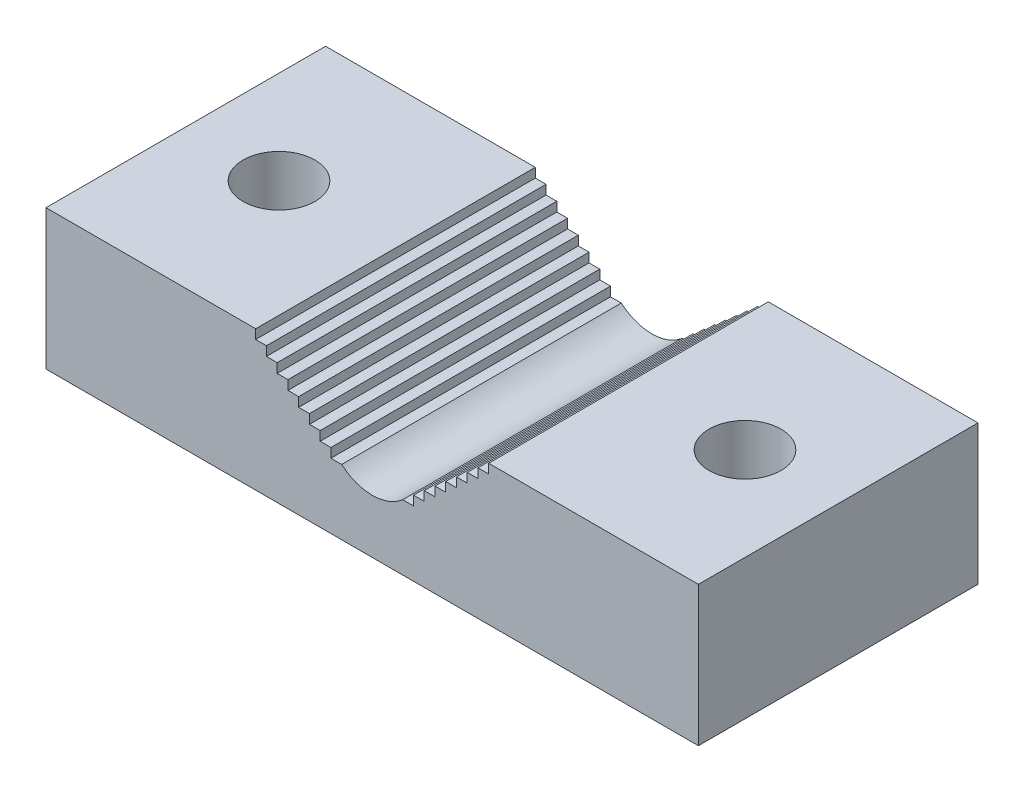
from build123d import *

# Parameters (mm, degrees)
SKETCH1_W               = 88.9
SKETCH1_H               = 19.05
BOSS_EXTRUDE1_DEPTH     = 38.1
CUT_EXTRUDE1_REACH      = 40.1
F_3_8_CLEARANCE_HOLE1_D = 9.8044


with BuildPart() as part:
    # Sketch1 → Boss-Extrude1 (new body)
    with BuildSketch(Plane.XY):
        with Locations((0, 9.525)):
            Rectangle(SKETCH1_W, SKETCH1_H)
    extrude(amount=-BOSS_EXTRUDE1_DEPTH)

    # Sketch2 → Cut-Extrude1 (cut, up to next)
    with BuildSketch(Plane.XY, mode=Mode.PRIVATE) as cut_extrude1_sk1:
        with BuildLine():
            Line((-15.875, 19.05), (0, 19.05))
            Line((0, 19.05), (15.875, 19.05))
            Line((15.875, 19.05), (15.875, 17.78))
            Line((15.875, 17.78), (14.410694861, 17.78))
            Line((14.410694861, 17.78), (14.410694861, 16.51))
            Line((14.410694861, 16.51), (12.946389723, 16.51))
            Line((12.946389723, 16.51), (12.946389723, 15.24))
            Line((12.946389723, 15.24), (11.482084584, 15.24))
            Line((11.482084584, 15.24), (11.482084584, 13.97))
            Line((11.482084584, 13.97), (10.017779445, 13.97))
            Line((10.017779445, 13.97), (10.017779445, 12.7))
            Line((10.017779445, 12.7), (8.553474306, 12.7))
            Line((8.553474306, 12.7), (8.553474306, 11.43))
            Line((8.553474306, 11.43), (7.089169168, 11.43))
            Line((7.089169168, 11.43), (7.089169168, 10.16))
            Line((7.089169168, 10.16), (5.624864029, 10.16))
            Line((5.624864029, 10.16), (5.624864029, 8.89))
            Line((5.624864029, 8.89), (4.16055889, 8.89))
            ThreePointArc((4.16055889, 8.89), (0, 7.337108475), (-4.16055889, 8.89))
            Line((-4.16055889, 8.89), (-5.624864029, 8.89))
            Line((-5.624864029, 8.89), (-5.624864029, 10.16))
            Line((-5.624864029, 10.16), (-7.089169168, 10.16))
            Line((-7.089169168, 10.16), (-7.089169168, 11.43))
            Line((-7.089169168, 11.43), (-8.553474306, 11.43))
            Line((-8.553474306, 11.43), (-8.553474306, 12.7))
            Line((-8.553474306, 12.7), (-10.017779445, 12.7))
            Line((-10.017779445, 12.7), (-10.017779445, 13.97))
            Line((-10.017779445, 13.97), (-11.482084584, 13.97))
            Line((-11.482084584, 13.97), (-11.482084584, 15.24))
            Line((-11.482084584, 15.24), (-12.946389723, 15.24))
            Line((-12.946389723, 15.24), (-12.946389723, 16.51))
            Line((-12.946389723, 16.51), (-14.410694861, 16.51))
            Line((-14.410694861, 16.51), (-14.410694861, 17.78))
            Line((-14.410694861, 17.78), (-15.875, 17.78))
            Line((-15.875, 17.78), (-15.875, 19.05))
        make_face()
    cut_extrude1_tool1 = extrude(cut_extrude1_sk1.sketch, amount=-CUT_EXTRUDE1_REACH, mode=Mode.PRIVATE) & part.part
    add(cut_extrude1_tool1.solids().sort_by_distance((0, 14.620592, 0))[0], mode=Mode.SUBTRACT)

    # 3/8 Clearance Hole1 (through all)
    with Locations(Plane(origin=(0, 19.05, 0), x_dir=(1, 0, 0), z_dir=(0, 1, 0))):
        with Locations((-31.75, 19.05), (31.75, 19.05)):
            Hole(F_3_8_CLEARANCE_HOLE1_D / 2)


solid = part.part
